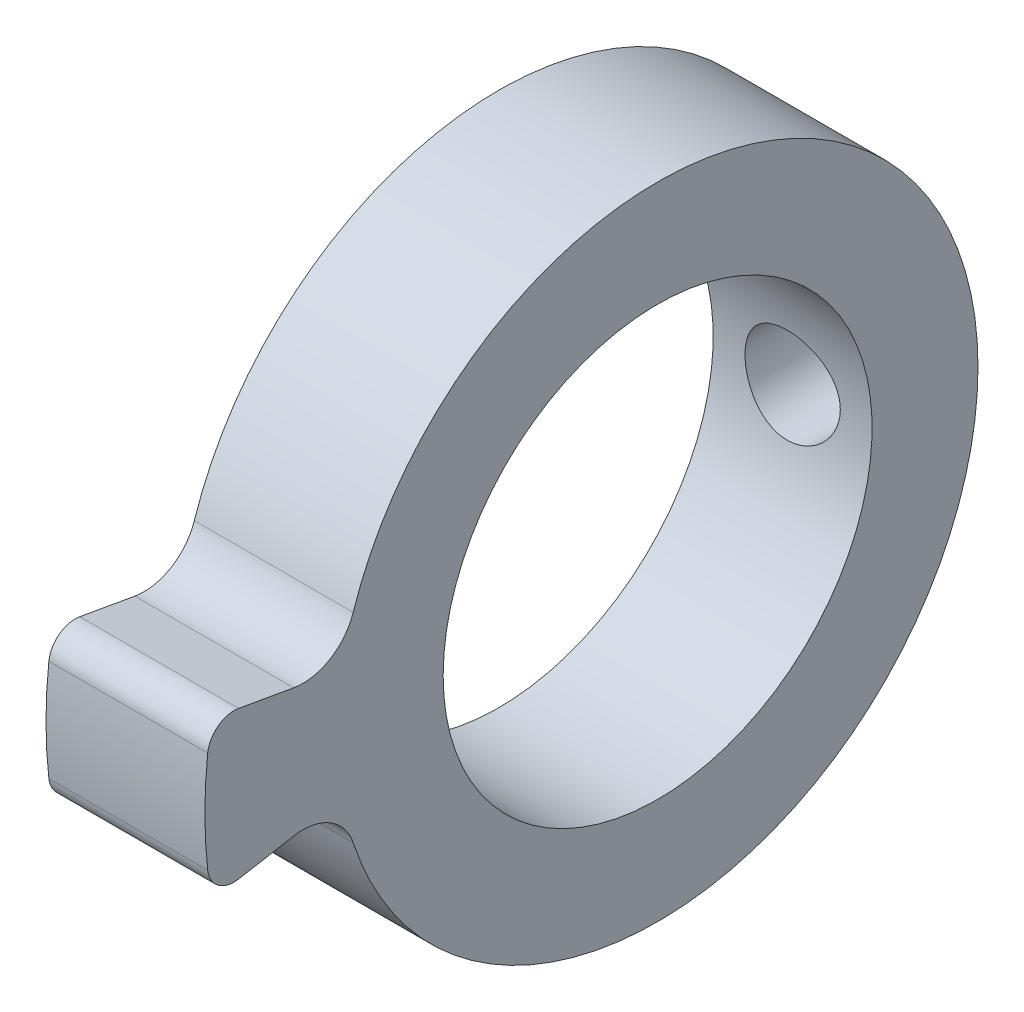
from build123d import *

# Parameters (mm, degrees)
ESQUISSE1_W        = 3
ESQUISSE1_H        = 2
BOSS_EXTRU_1_DEPTH = 3
CONG_1_R           = 1
CONG_3_R           = 0.5
ESQUISSE4_W        = 0.9
ESQUISSE4_H        = 6.05


with BuildPart() as part:
    # Esquisse1 → Révolution1 (revolve)
    with BuildSketch(Plane.XY):
        with Locations((1.5, 5.05)):
            Rectangle(ESQUISSE1_W, ESQUISSE1_H)
    revolve(axis=Axis((-3.996004355, 0, 0), (1, 0, 0)))

    # Esquisse2 → Boss.-Extru.1 (add)
    with BuildSketch(Plane.ZY):
        with BuildLine():
            Line((5.958086906, -1.050571475), (8.420106288, -1.484691919))
            ThreePointArc((8.420106288, -1.484691919), (8.55, 0), (8.420106288, 1.484691919))
            Line((8.420106288, 1.484691919), (5.958086906, 1.050571475))
            ThreePointArc((5.958086906, 1.050571475), (6.05, 0), (5.958086906, -1.050571475))
        make_face()
    extrude(amount=-BOSS_EXTRU_1_DEPTH)

    # Congé1
    cong_1_edges = [part.edges().sort_by_distance(p)[0] for p in [
        (1.5, -1.050571475, 5.958086906),
        (1.5, 1.050571475, 5.958086906),
    ]]
    fillet(cong_1_edges, radius=CONG_1_R)

    # Congé3
    cong_3_edges = [part.edges().sort_by_distance(p)[0] for p in [
        (1.5, 1.484691919, 8.420106288),
        (1.5, -1.484691919, 8.420106288),
    ]]
    fillet(cong_3_edges, radius=CONG_3_R)

    # Esquisse4 → Dégagement M21 (revolve, cut)
    with BuildSketch(Plane(origin=(1.5, 0, 0), x_dir=(0, -1, 0), z_dir=(1, 0, 0))):
        with Locations((0.45, 3.025)):
            Rectangle(ESQUISSE4_W, ESQUISSE4_H)
    revolve(axis=Axis((1.5, 0, 6.35), (0, 0, -1)), mode=Mode.SUBTRACT)


solid = part.part
